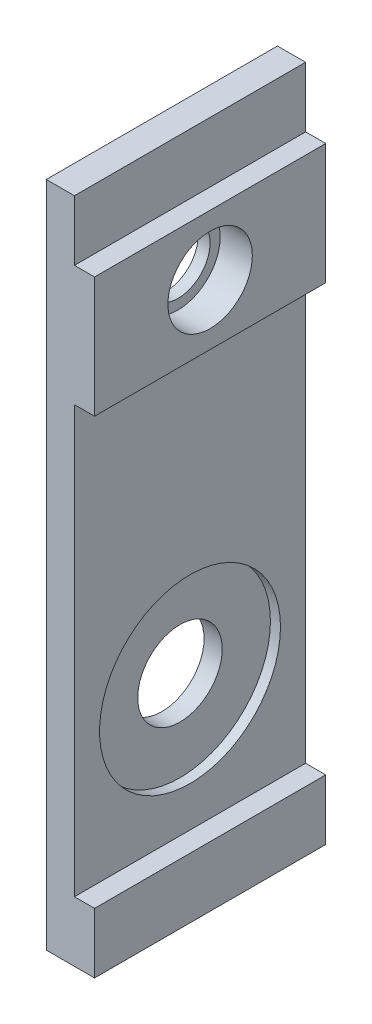
from build123d import *

# Parameters (mm, degrees)
SALIENTE_EXTRUIR1_DEPTH = 11.5
CORTAR_EXTRUIR1_START   = -2.4
CROQUIS2_R              = 2.1
CORTAR_EXTRUIR1_DEPTH   = 2.4
CROQUIS3_R              = 4.5
CORTAR_EXTRUIR2_DEPTH   = 0.5
CROQUIS4_R              = 3
CORTAR_EXTRUIR3_DEPTH   = 0.2
CROQUIS5_R              = 2.1
CROQUIS5_R_2            = 1.6
SALIENTE_EXTRUIR2_DEPTH = 0.6


with BuildPart() as part:
    # Croquis1 → Saliente-Extruir1 (new body)
    with BuildSketch(Plane.XY):
        Polygon((-89.253382482, -13.336480186), (-89.253382482, 19.863519814), (-87.853382482, 19.863519814), (-87.853382482, 16.863519814), (-86.853382482, 16.863519814), (-86.853382482, 10.863519814), (-87.853382482, 10.863519814), (-87.853382482, -10.336480186), (-86.853382482, -10.336480186), (-86.853382482, -13.336480186), align=None)
    extrude(amount=SALIENTE_EXTRUIR1_DEPTH)

    # Croquis2 → Cortar-Extruir1 (cut)
    with BuildSketch(Plane(origin=(-86.853382482, 0, 0), x_dir=(0, 0, -1), z_dir=(1, 0, 0)).offset(CORTAR_EXTRUIR1_START)):
        with Locations((-5.75, 13.863519814)):
            Circle(CROQUIS2_R)
        with Locations((-5.75, -3.836480186)):
            Circle(CROQUIS2_R)
    extrude(amount=CORTAR_EXTRUIR1_DEPTH, mode=Mode.SUBTRACT)

    # Croquis3 → Cortar-Extruir2 (cut)
    with BuildSketch(Plane(origin=(-87.853382482, 0, 0), x_dir=(0, 0, -1), z_dir=(1, 0, 0))):
        with Locations((-5.75, -3.836480186)):
            Circle(CROQUIS3_R)
    extrude(amount=-CORTAR_EXTRUIR2_DEPTH, mode=Mode.SUBTRACT)

    # Croquis4 → Cortar-Extruir3 (cut)
    with BuildSketch(Plane.ZY.offset(89.253382482)):
        with Locations((5.75, 13.863519814)):
            Circle(CROQUIS4_R)
    extrude(amount=-CORTAR_EXTRUIR3_DEPTH, mode=Mode.SUBTRACT)

    # Croquis5 → Saliente-Extruir2 (add)
    with BuildSketch(Plane.ZY.offset(89.053382482)):
        with Locations((5.75, 13.863519814)):
            Circle(CROQUIS5_R)
        with Locations((5.75, 13.863519814)):
            Circle(CROQUIS5_R_2, mode=Mode.SUBTRACT)
    extrude(amount=-SALIENTE_EXTRUIR2_DEPTH)


solid = part.part
